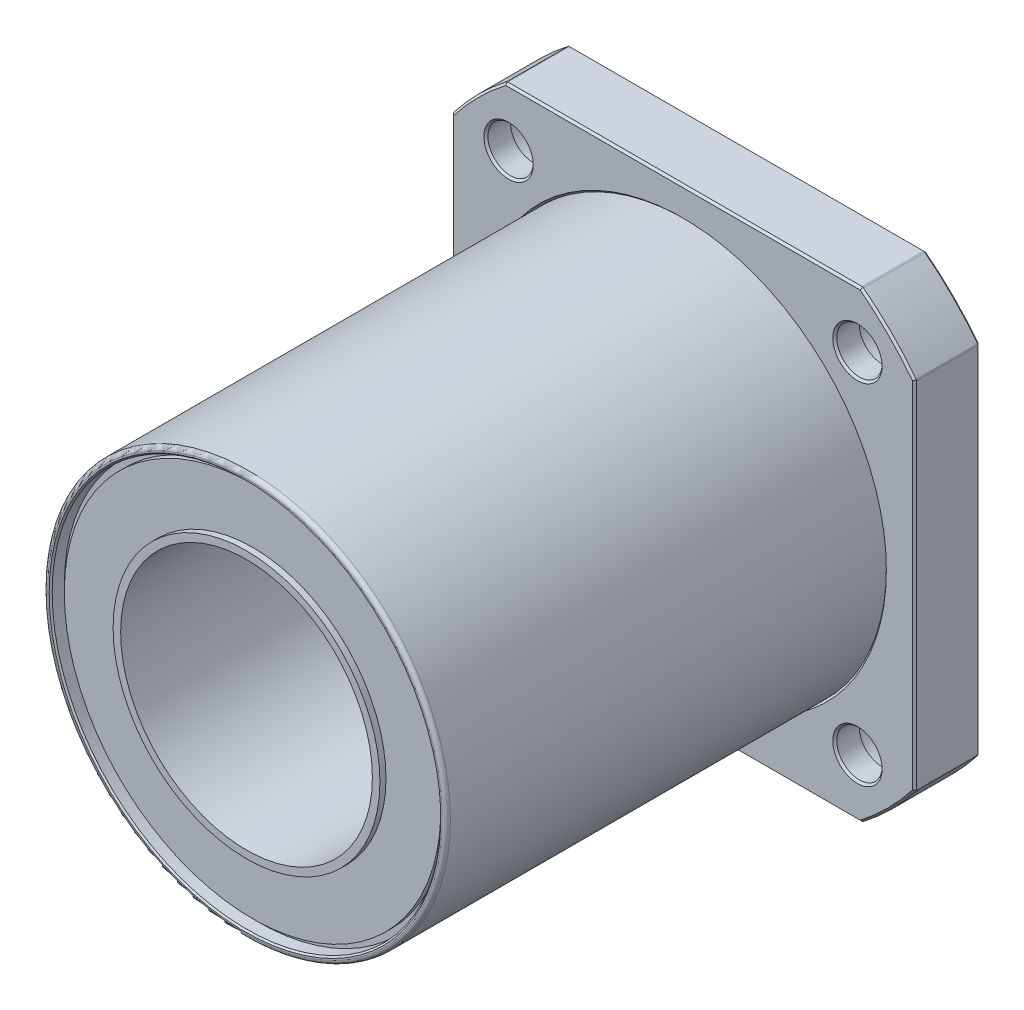
from build123d import *

# Parameters (mm, degrees)
SKETCH_1_W          = 92
SKETCH_1_H          = 92
SKETCH_1_R          = 40
EXTRUDE_1_DEPTH     = 13
SKETCH_3_OUTSIDE_W  = 120.152
SKETCH_3_OUTSIDE_H  = 120.152
SKETCH_3_OUTSIDE_R  = 58
CUT_EXTRUDE_2_DEPTH = 13
SKETCH_5_R          = 4.5
CUT_EXTRUDE_3_DEPTH = 13
SKETCH_5_3_R        = 7
SKETCH_5_3_R_2      = 4.5
CUT_EXTRUDE_4_DEPTH = 8.1
CHAMFER_1_SIZE      = 0.4
SKETCH_7_R          = 40
SKETCH_7_R_2        = 38.6
EXTRUDE_2_DEPTH     = 100
FILLET_1_R          = 0.8
CHAMFER_2_SIZE      = 0.3
FILLET_2_R          = 0.4


with BuildPart() as part:
    # Sketch 1 → Extrude 1 (new body)
    with BuildSketch(Plane.XY):
        Rectangle(SKETCH_1_W, SKETCH_1_H)
        Circle(SKETCH_1_R, mode=Mode.SUBTRACT)
    extrude(amount=EXTRUDE_1_DEPTH)

    # Sketch 3 outside → Cut-Extrude 2 (cut)
    with BuildSketch(Plane.XY.offset(13)):
        Rectangle(SKETCH_3_OUTSIDE_W, SKETCH_3_OUTSIDE_H)
        Circle(SKETCH_3_OUTSIDE_R, mode=Mode.SUBTRACT)
    extrude(amount=-CUT_EXTRUDE_2_DEPTH, mode=Mode.SUBTRACT)

    # Sketch 5 → Cut-Extrude 3 (cut)
    with BuildSketch(Plane.XY):
        with Locations(Location((-34.648232278, 34.648232278, 0), (0, 0, 180))):  # turned: the seam where the file's is
            Circle(SKETCH_5_R)
        with Locations(Location((-34.648232278, -34.648232278, 0), (0, 0, 180))):  # turned: the seam where the file's is
            Circle(SKETCH_5_R)
        with Locations(Location((34.648232278, -34.648232278, 0), (0, 0, 180))):  # turned: the seam where the file's is
            Circle(SKETCH_5_R)
        with Locations(Location((34.648232278, 34.648232278, 0), (0, 0, 180))):  # turned: the seam where the file's is
            Circle(SKETCH_5_R)
    extrude(amount=CUT_EXTRUDE_3_DEPTH, mode=Mode.SUBTRACT)

    # Sketch 5_3 → Cut-Extrude 4 (cut)
    with BuildSketch(Plane.XY):
        with Locations((-34.648232278, 34.648232278)):
            Circle(SKETCH_5_3_R)
        with Locations(Location((-34.648232278, 34.648232278, 0), (0, 0, 180))):  # turned: the seam where the file's is
            Circle(SKETCH_5_3_R_2, mode=Mode.SUBTRACT)
        with Locations(Location((34.648232278, 34.648232278, 0), (0, 0, 180))):  # turned: the seam where the file's is
            Circle(SKETCH_5_3_R)
        with Locations(Location((34.648232278, 34.648232278, 0), (0, 0, 180))):  # turned: the seam where the file's is
            Circle(SKETCH_5_3_R_2, mode=Mode.SUBTRACT)
        with Locations((34.648232278, -34.648232278)):
            Circle(SKETCH_5_3_R)
        with Locations(Location((34.648232278, -34.648232278, 0), (0, 0, 180))):  # turned: the seam where the file's is
            Circle(SKETCH_5_3_R_2, mode=Mode.SUBTRACT)
        with Locations(Location((-34.648232278, -34.648232278, 0), (0, 0, 180))):  # turned: the seam where the file's is
            Circle(SKETCH_5_3_R)
        with Locations(Location((-34.648232278, -34.648232278, 0), (0, 0, 180))):  # turned: the seam where the file's is
            Circle(SKETCH_5_3_R_2, mode=Mode.SUBTRACT)
    extrude(amount=CUT_EXTRUDE_4_DEPTH, mode=Mode.SUBTRACT)

    # Chamfer 1
    chamfer_1_edges = [part.edges().sort_by_distance(p)[0] for p in [
        (41.648232278, 34.648232278, 0),
        (-41.648232278, 34.648232278, 0),
        (-40, 0, 0),
        (-40, 0, 13),
        (0, -46, 0),
        (0, -46, 13),
        (-46, 0, 0),
        (-46, 0, 13),
        (0, 46, 0),
        (0, 46, 13),
        (46, 0, 0),
        (46, 0, 13),
        (41.012193309, -41.012193309, 13),
        (41.012193309, 41.012193309, 13),
        (-41.012193309, 41.012193309, 13),
        (-41.012193309, -41.012193309, 13),
        (41.012193309, 41.012193309, 0),
        (-41.012193309, 41.012193309, 0),
        (41.012193309, -41.012193309, 0),
        (-41.012193309, -41.012193309, 0),
        (39.148232278, 34.648232278, 13),
        (39.148232278, -34.648232278, 13),
        (-30.148232278, -34.648232278, 13),
        (-30.148232278, 34.648232278, 13),
        (-27.648232278, -34.648232278, 0),
        (27.648232278, -34.648232278, 0),
    ]]
    chamfer(chamfer_1_edges, length=CHAMFER_1_SIZE)

    # Sketch 7 → Extrude 2 (add)
    with BuildSketch(Plane(origin=(0, 0, 0), x_dir=(-1, 0, 0), z_dir=(0, 0, -1))):
        Circle(SKETCH_7_R)
        Circle(SKETCH_7_R_2, mode=Mode.SUBTRACT)
    extrude(amount=-EXTRUDE_2_DEPTH)

    # Fillet 1
    fillet_1_edges = [part.edges().sort_by_distance(p)[0] for p in [
        (40, 0, 100),
    ]]
    fillet(fillet_1_edges, radius=FILLET_1_R)

    # Chamfer 2
    chamfer_2_edges = [part.edges().sort_by_distance(p)[0] for p in [
        (38.6, 0, 100),
    ]]
    chamfer(chamfer_2_edges, length=CHAMFER_2_SIZE)

    # Sketch 8 → Revolve 1 (revolve)
    with BuildSketch(Plane(origin=(0, 0, 0), x_dir=(0, 0, -1), z_dir=(1, 0, 0)), mode=Mode.PRIVATE) as revolve_1_sk:
        Polygon((-97.3, 38.6), (-2.4, 38.6), (-2.4, 37.4), (-1.2, 37.4), (-1.2, 26.5), (0, 26.5), (0, 25), (-99.7, 25), (-99.7, 26.5), (-98.5, 26.5), (-98.5, 37.4), (-97.3, 37.4), align=None)
    revolve(revolve_1_sk.sketch.rotate(Axis((0, 0, 0), (0, 0, 1)), 90), axis=Axis((0, 0, 0), (0, 0, 1)))  # turned: the seam where the file's is

    # Fillet 2
    fillet_2_edges = [part.edges().sort_by_distance(p)[0] for p in [
        (-35.327043465, 46, 6.5),
        (-46, 35.327043465, 6.5),
        (-46, -35.327043465, 6.5),
        (-35.327043465, -46, 6.5),
        (35.327043465, -46, 6.5),
        (46, -35.327043465, 6.5),
        (46, 35.327043465, 6.5),
        (35.327043465, 46, 6.5),
    ]]
    fillet(fillet_2_edges, radius=FILLET_2_R)


solid = part.part
